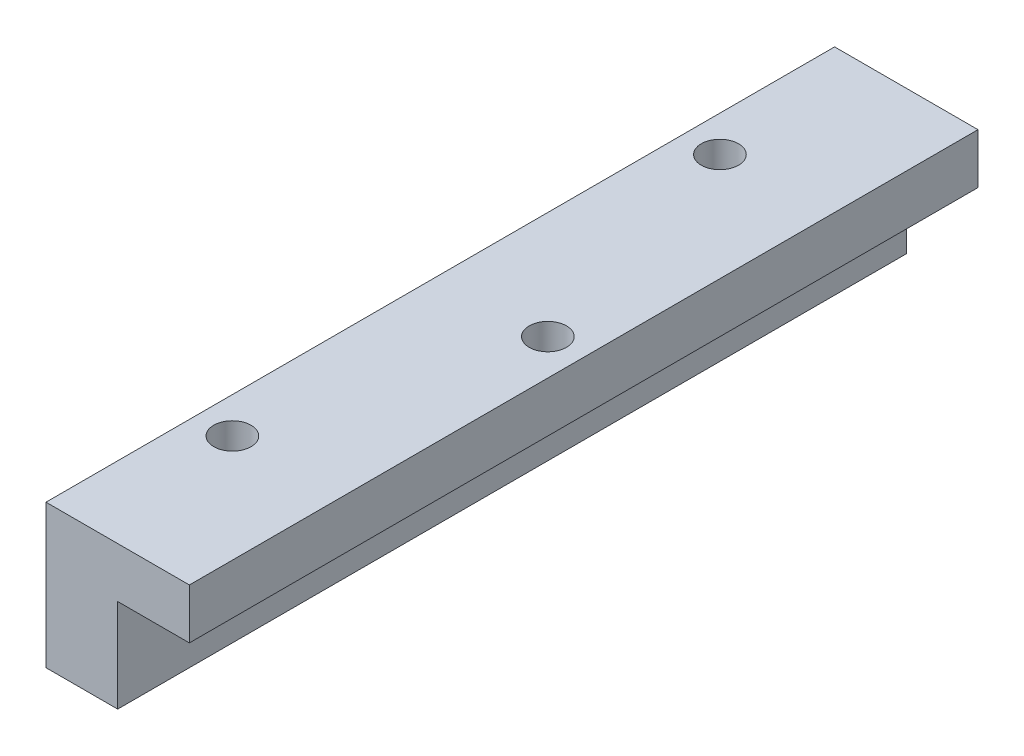
from build123d import *

# Parameters (mm, degrees)
BOSS_EXTRUDE1_DEPTH = 110
SKETCH2_R           = 2.6
CUT_EXTRUDE1_DEPTH  = 110
CUT_EXTRUDE2_START  = -7
CUT_EXTRUDE2_DEPTH  = 3
SKETCH4_R           = 2.6
CUT_EXTRUDE3_DEPTH  = 13


with BuildPart() as part:
    # Sketch1 → Boss-Extrude1 (new body)
    with BuildSketch(Plane.XY):
        Polygon((0, 0), (10, 0), (10, 13), (20, 13), (20, 20), (10, 20), (0, 20), align=None)
    extrude(amount=BOSS_EXTRUDE1_DEPTH)

    # Sketch2 → Cut-Extrude1 (cut)
    with BuildSketch(Plane(origin=(0, 20, 0), x_dir=(1, 0, 0), z_dir=(0, 1, 0))):
        with Locations((5, -21)):
            Circle(SKETCH2_R)
        with Locations((5, -89)):
            Circle(SKETCH2_R)
    extrude(amount=-CUT_EXTRUDE1_DEPTH, mode=Mode.SUBTRACT)

    # Sketch3 → Cut-Extrude2 (cut)
    with BuildSketch(Plane(origin=(0, 20, 0), x_dir=(1, 0, 0), z_dir=(0, 1, 0)).offset(CUT_EXTRUDE2_START)):
        Polygon((15, -50.438932873), (11.05, -52.719466437), (11.05, -57.280533563), (15, -59.561067127), (18.95, -57.280533563), (18.95, -52.719466437), align=None)
    extrude(amount=CUT_EXTRUDE2_DEPTH, mode=Mode.SUBTRACT)

    # Sketch4 → Cut-Extrude3 (cut)
    with BuildSketch(Plane.XZ.offset(-16)):
        with Locations((15, 55)):
            Circle(SKETCH4_R)
    extrude(amount=-CUT_EXTRUDE3_DEPTH, mode=Mode.SUBTRACT)


solid = part.part
